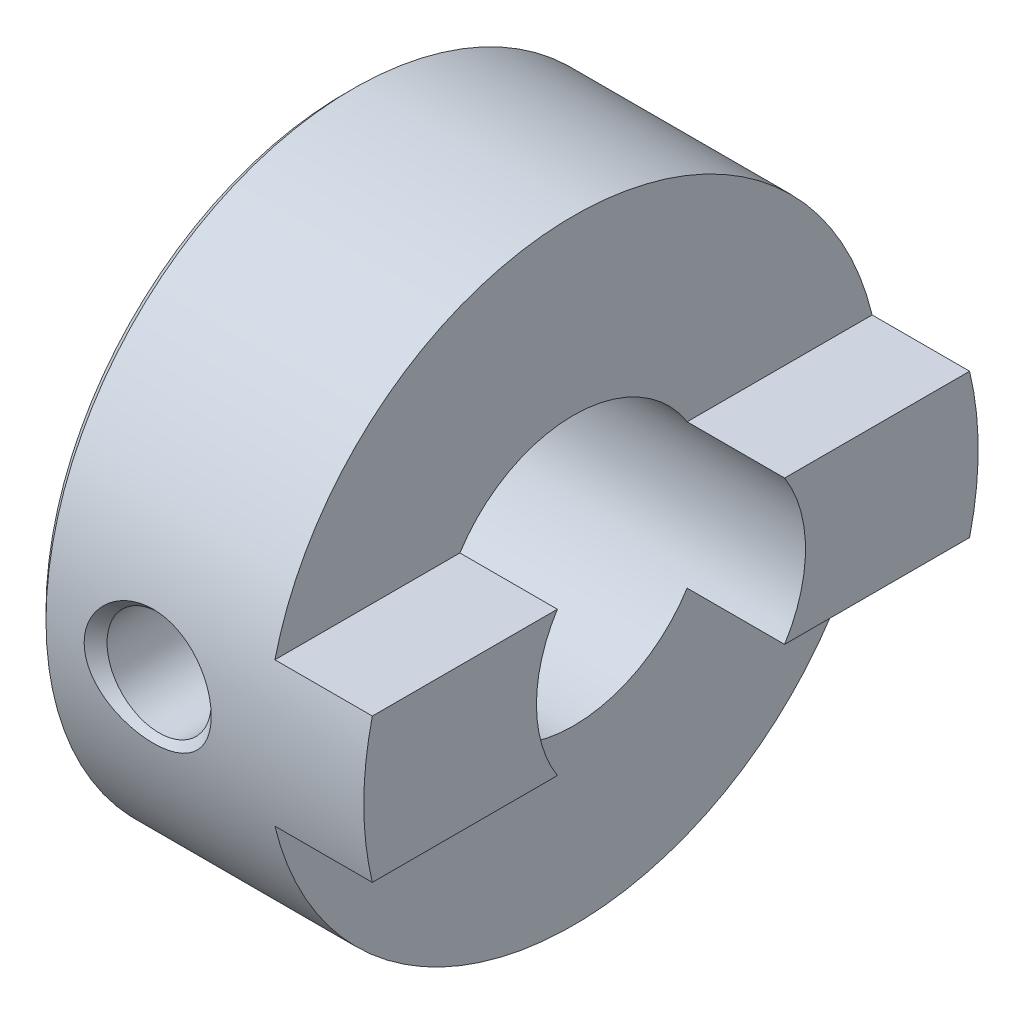
from build123d import *

# Parameters (mm, degrees)
SKETCH2_W          = 16.5
SKETCH2_H          = 15.5
SKETCH2_W_2        = 14.5
SKETCH2_H_2        = 3.4
CUT_EXTRUDE1_DEPTH = 2.3


with BuildPart() as part:
    # Sketch1 → Revolve1 (revolve)
    with BuildSketch(Plane.XY):
        Polygon((0, 7.05), (0, 3.175), (7.7, 3.175), (7.7, 7.25), (0.2, 7.25), align=None)
    revolve(axis=Axis((7.7, 0, 0), (-1, 0, 0)))

    # Sketch2 → Cut-Extrude1 (cut)
    with BuildSketch(Plane(origin=(7.7, 0, 0), x_dir=(0, 0, -1), z_dir=(1, 0, 0))):
        Rectangle(SKETCH2_W, SKETCH2_H)
        Rectangle(SKETCH2_W_2, SKETCH2_H_2, mode=Mode.SUBTRACT)
    extrude(amount=-CUT_EXTRUDE1_DEPTH, mode=Mode.SUBTRACT)

    # Sketch3 → Cut-Revolve1 (revolve, cut)
    with BuildSketch(Plane(origin=(2.6, 0, 0), x_dir=(0, 0, -1), z_dir=(1, 0, 0))):
        Polygon((-7.25, 0), (-7.25, 1.5), (-6.9795, 1.2295), (0, 1.2295), (0, 0), align=None)
    revolve(axis=Axis((2.6, 0, 0), (0, 0, 1)), mode=Mode.SUBTRACT)

    # Sketch4 → Cut-Revolve2 (revolve, cut)
    with BuildSketch(Plane(origin=(2.6, 0, 0), x_dir=(0, 0, -1), z_dir=(1, 0, 0))):
        Polygon((0, -7.25), (-1.5, -7.25), (-1.2295, -6.9795), (-1.2295, 0), (0, 0), align=None)
    revolve(axis=Axis((2.6, 0, 0), (0, -1, 0)), mode=Mode.SUBTRACT)


solid = part.part
